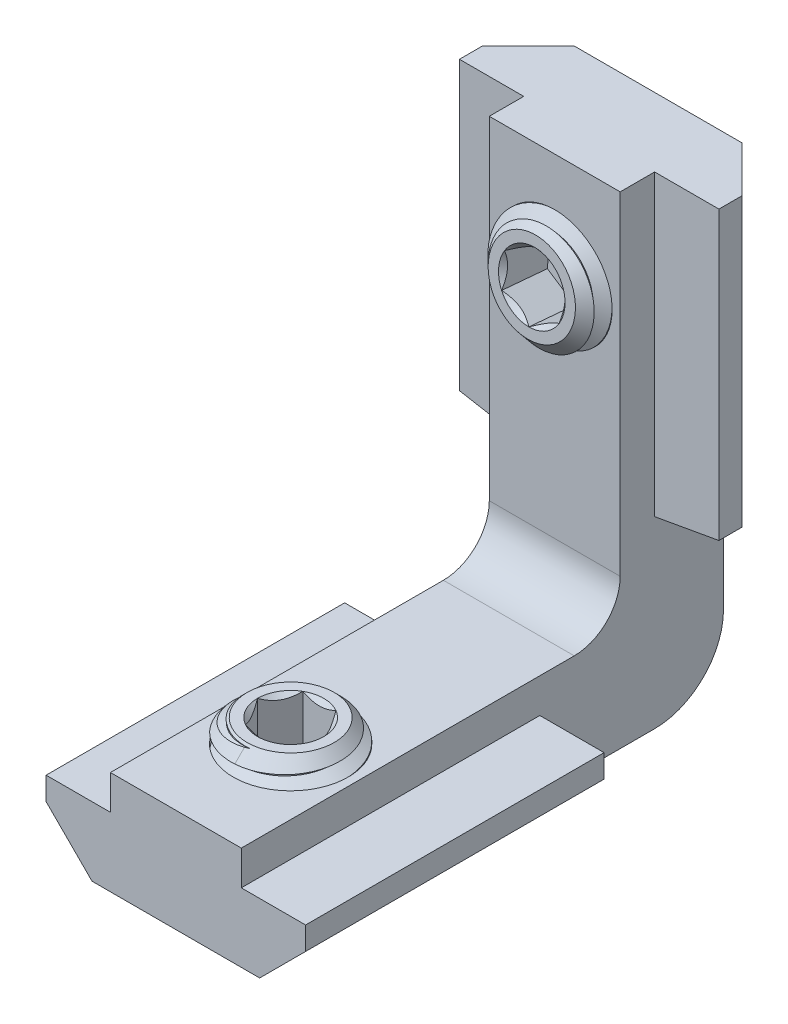
from build123d import *

# Parameters (mm, degrees)
BOSS_EXTRUDE1_DEPTH      = 13
SKETCH2_R                = 2.5
CUT_EXTRUDE1_DEPTH       = 23.207487476
BOSS_EXTRUDE2_DEPTH      = 13
CUT_EXTRUDE2_DEPTH       = 28.297847901
BOSS_EXTRUDE3_DEPTH      = 2.85
BOSS_EXTRUDE3_DEPTH_BACK = 2.85
CUT_SWEEP1_PITCH         = 0.8
CUT_SWEEP1_HEIGHT        = 5.8
CUT_SWEEP1_RADIUS        = 2.5
SKETCH11_OUTSIDE_W       = 75.066
SKETCH11_OUTSIDE_H       = 84.766
SKETCH11_OUTSIDE_R       = 1.893782217
CUT_EXTRUDE3_DEPTH       = 27.705289738
CUT_EXTRUDE3_DRAFT       = -45
CUT_EXTRUDE4_DEPTH       = 2
CUT_SWEEP2_PITCH         = 0.8
CUT_SWEEP2_HEIGHT        = 5.8
CUT_SWEEP2_RADIUS        = 2.5
CUT_SWEEP2_START_ANGLE   = 180
SKETCH17_OUTSIDE_W       = 72.53
SKETCH17_OUTSIDE_H       = 83.98
SKETCH17_OUTSIDE_R       = 1.893782217
CUT_EXTRUDE6_DEPTH       = 26.437892798
CUT_EXTRUDE6_DRAFT       = -45
CUT_EXTRUDE7_DEPTH       = 2


with BuildPart() as part:
    # Sketch1 → Boss-Extrude1 (new body)
    with BuildSketch(Plane.XY.offset(21)):
        Polygon((-2.85, 4.5), (2.85, 4.5), (2.85, 3), (5.65, 3), (5.65, 2), (3.65, 0), (-3.65, 0), (-5.65, 2), (-5.65, 3), (-2.85, 3), align=None)
    extrude(amount=-BOSS_EXTRUDE1_DEPTH)

    # Sketch2 → Cut-Extrude1 (cut, through all)
    with BuildSketch(Plane(origin=(0, 4.5, 0), x_dir=(1, 0, 0), z_dir=(0, 1, 0))):
        with Locations(Location((0, -16, 0), (0, 0, 180))):
            Circle(SKETCH2_R)
    extrude(amount=-CUT_EXTRUDE1_DEPTH, mode=Mode.SUBTRACT)



with BuildPart() as body_2:
    # Sketch3 → Boss-Extrude2 (new body)
    with BuildSketch(Plane(origin=(0, 21, 0), x_dir=(-1, 0, 0), z_dir=(0, 1, 0))):
        Polygon((2.85, 4.5), (-2.85, 4.5), (-2.85, 3), (-5.65, 3), (-5.65, 2), (-3.65, 0), (3.65, 0), (5.65, 2), (5.65, 3), (2.85, 3), align=None)
    extrude(amount=-BOSS_EXTRUDE2_DEPTH)

    # Sketch5 → Cut-Revolve1 (revolve, cut)
    with BuildSketch(Plane(origin=(0, 0, 0), x_dir=(0, 0, -1), z_dir=(1, 0, 0))):
        Polygon((-4.717889357, 16.412761834), (0.217889357, 15.980937151), (0.435778714, 18.471423897), (-4.5, 18.90324858), align=None)
    revolve(axis=Axis((0, 16.528464222, 6.040373696), (0, -0.08715574274765803, -0.9961946980917455)), mode=Mode.SUBTRACT)

    # Sketch6 → Cut-Extrude2 (cut, through all)
    with BuildSketch(Plane.XY.offset(4.5)):
        Polygon((-5.65, 8), (-5.65, 8.5), (-2.85, 8), align=None)
        Polygon((2.85, 8), (5.65, 8), (5.65, 8.5), align=None)
    extrude(amount=-CUT_EXTRUDE2_DEPTH, mode=Mode.SUBTRACT)


with BuildPart() as part_1:
    add(part.part)

    add(body_2.part)  # Boss-Extrude3 merges body 2
    # Sketch7 → Boss-Extrude3 (add, two sides: drawn at the far end of the back side and taken through both)
    with BuildSketch(Plane(origin=(0, 0, 0), x_dir=(0, 0, -1), z_dir=(1, 0, 0)).offset(-BOSS_EXTRUDE3_DEPTH_BACK)):
        with BuildLine():
            Line((-8, 0), (-3, 0))
            ThreePointArc((-3, 0), (-0.878679656, 0.878679656), (0, 3))
            Line((0, 3), (0, 8))
            Line((0, 8), (-4.5, 8))
            Line((-4.5, 8), (-4.5, 6.5))
            ThreePointArc((-4.5, 6.5), (-5.085786438, 5.085786438), (-6.5, 4.5))
            Line((-6.5, 4.5), (-8, 4.5))
            Line((-8, 4.5), (-8, 0))
        make_face()
    extrude(amount=BOSS_EXTRUDE3_DEPTH + BOSS_EXTRUDE3_DEPTH_BACK)


with BuildPart() as body_2_2:
    # Sketch8 → Revolve1 (revolve)
    with BuildSketch(Plane(origin=(0, 0, 0), x_dir=(0, 0, -1), z_dir=(1, 0, 0))):
        Polygon((-16, 5.5), (-18.5, 5.5), (-18.5, 1.25), (-17.75, 0.5), (-16, 0.5), align=None)
    revolve(axis=Axis((0, 10.889007752, 16), (0, -1, 0)))

    # Cut-Sweep1: sweep along a helix
    with BuildLine() as cut_sweep1_path:
        Helix(CUT_SWEEP1_PITCH, CUT_SWEEP1_HEIGHT, CUT_SWEEP1_RADIUS, center=(0, 5.5, 16), direction=(0, -1, 0))
    # Sketch10 → Cut-Sweep1 (sweep, cut)
    with BuildSketch(Plane(origin=(0, 0, 0), x_dir=(0, 0, -1), z_dir=(1, 0, 0))):
        Polygon((-14.019615242, 5.9), (-14.019615242, 5.8), (-13.45669873, 5.475), (-13.45669873, 6.225), align=None)
    sweep(path=cut_sweep1_path.line, is_frenet=True, mode=Mode.SUBTRACT)


with BuildPart() as cut_extrude3_tool:
    # Sketch11 outside → Cut-Extrude3 (with draft: the straight prism first)
    with BuildSketch(Plane(origin=(0, 5.5, 0), x_dir=(1, 0, 0), z_dir=(0, 1, 0))):
        with Locations((0, -10.5)):
            Rectangle(SKETCH11_OUTSIDE_W, SKETCH11_OUTSIDE_H)
        with Locations((0, -16)):
            Circle(SKETCH11_OUTSIDE_R, mode=Mode.SUBTRACT)
    extrude(amount=-CUT_EXTRUDE3_DEPTH)
    # Cut-Extrude3: the draft: its side faces are tilted about the plane it starts from
    cut_extrude3_sides = [cut_extrude3_tool.faces().sort_by_distance(p)[0] for p in [
        (0, -8.352644869, 52.883),
        (37.533, -8.352644869, 10.5),
        (0, -8.352644869, -31.883),
        (-37.533, -8.352644869, 10.5),
        (-1.893782217, -8.352644869, 16),
    ]]
    draft(cut_extrude3_sides, Plane(origin=(0, 5.5, 0), x_dir=(1, 0, 0), z_dir=(0, 1, 0)), CUT_EXTRUDE3_DRAFT)


with BuildPart() as body_2_2_1:
    add(body_2_2.part)

    # Cut-Extrude3: cut by cut_extrude3_tool
    add(cut_extrude3_tool.part, mode=Mode.SUBTRACT)

    # Sketch12 → Cut-Extrude4 (cut)
    with BuildSketch(Plane(origin=(0, 5.5, 0), x_dir=(1, 0, 0), z_dir=(0, 1, 0))):
        Polygon((1.443375673, -16), (0.721687836, -14.75), (-0.721687836, -14.75), (-1.443375673, -16), (-0.721687836, -17.25), (0.721687836, -17.25), align=None)
    extrude(amount=-CUT_EXTRUDE4_DEPTH, mode=Mode.SUBTRACT)

    # Cut-Extrude5 cone 1 section (through the dimple's axis) → Cut-Extrude5 (revolve, cut)
    with BuildSketch(Plane(origin=(0, 5.5, 16), x_dir=(0, 0, 1), z_dir=(1, 0, 0))):
        Polygon((0, 0), (1.443375673, 0), (0, 1.443375673), align=None)
    revolve(axis=Axis((0, 5.5, 16), (0, -1, 0)), mode=Mode.SUBTRACT)


with BuildPart() as body_3:
    # Sketch14 → Revolve2 (revolve)
    with BuildSketch(Plane(origin=(0, 0, 0), x_dir=(0, 0, -1), z_dir=(1, 0, 0)), mode=Mode.PRIVATE) as revolve2_sk:
        Polygon((-1.048283176, 18.601262488), (-0.36650396, 17.788749657), (-0.51902651, 16.045408936), (-5.5, 16.481187649), (-5.282110643, 18.971674395), align=None)
    revolve(revolve2_sk.sketch.rotate(Axis((0, 16.959847914, 10.97111186), (0, -0.08715574274765783, -0.9961946980917457)), 180), axis=Axis((0, 16.959847914, 10.97111186), (0, -0.08715574274765783, -0.9961946980917457)))

    # Cut-Sweep2: sweep along a helix
    with BuildLine() as cut_sweep2_path:
        add(Helix(CUT_SWEEP2_PITCH, CUT_SWEEP2_HEIGHT, CUT_SWEEP2_RADIUS, center=(0, 16.481187649, 5.5), direction=(0, -0.08715574274765783, -0.9961946980917455), mode=Mode.PRIVATE).rotate(Axis((0, 16.481187649, 5.5), (0, -0.08715574274765783, -0.9961946980917455)), CUT_SWEEP2_START_ANGLE))
    # Sketch16 → Cut-Sweep2 (sweep, cut)
    with BuildSketch(Plane(origin=(0, 0, 0), x_dir=(0, 0, -1), z_dir=(1, 0, 0))):
        Polygon((-6.000577845, 19.077998804), (-5.725875975, 18.488898742), (-5.626256505, 18.480183168), (-5.253431821, 19.012631997), align=None)
    sweep(path=cut_sweep2_path.line, is_frenet=True, mode=Mode.SUBTRACT)


with BuildPart() as cut_extrude6_tool:
    # Sketch17 outside → Cut-Extrude6 (with draft: the straight prism first)
    with BuildSketch(Plane(origin=(0, 0.602725625, 6.889185421), x_dir=(1, 0, 0), z_dir=(0, 0.08715574274765783, 0.9961946980917455))):
        with Locations((0, 9.545)):
            Rectangle(SKETCH17_OUTSIDE_W, SKETCH17_OUTSIDE_H)
        with Locations((0, 15.939115169)):
            Circle(SKETCH17_OUTSIDE_R, mode=Mode.SUBTRACT)
    extrude(amount=-CUT_EXTRUDE6_DEPTH)
    # Cut-Extrude6: the draft: its side faces are tilted about the plane it starts from
    cut_extrude6_sides = [cut_extrude6_tool.faces().sort_by_distance(p)[0] for p in [
        (0, -32.870918446, -3.451690822),
        (36.265, 8.959296927, -7.11136046),
        (0, 50.7895123, -10.771030098),
        (-36.265, 8.959296927, -7.11136046),
        (-1.893782217, 15.329080558, -7.668644317),
    ]]
    draft(cut_extrude6_sides, Plane(origin=(0, 0.602725625, 6.889185421), x_dir=(1, 0, 0), z_dir=(0, 0.08715574274765783, 0.9961946980917455)), CUT_EXTRUDE6_DRAFT)


with BuildPart() as body_3_1:
    add(body_3.part)

    # Cut-Extrude6: cut by cut_extrude6_tool
    add(cut_extrude6_tool.part, mode=Mode.SUBTRACT)

    # Sketch18 → Cut-Extrude7 (cut)
    with BuildSketch(Plane(origin=(0, 0.602725625, 6.889185421), x_dir=(1, 0, 0), z_dir=(0, 0.08715574274765783, 0.9961946980917455))):
        Polygon((0, 17.382490842), (-1.25, 16.660803006), (-1.25, 15.217427333), (0, 14.495739496), (1.25, 15.217427333), (1.25, 16.660803006), align=None)
    extrude(amount=-CUT_EXTRUDE7_DEPTH, mode=Mode.SUBTRACT)

    # Cut-Extrude8 cone 1 section (through the dimple's axis) → Cut-Extrude8 (revolve, cut)
    with BuildSketch(Plane(origin=(0, 16.481187649, 5.5), x_dir=(0, -0.996194698, 0.087155743), z_dir=(1, 0, 0))):
        Polygon((0, 0), (1.443375673, 0), (0, 1.443375673), align=None)
    revolve(axis=Axis((0, 16.481187649, 5.5), (0, -0.087155743, -0.996194698)), mode=Mode.SUBTRACT)


solid = Compound([part_1.part, body_2_2_1.part, body_3_1.part])
